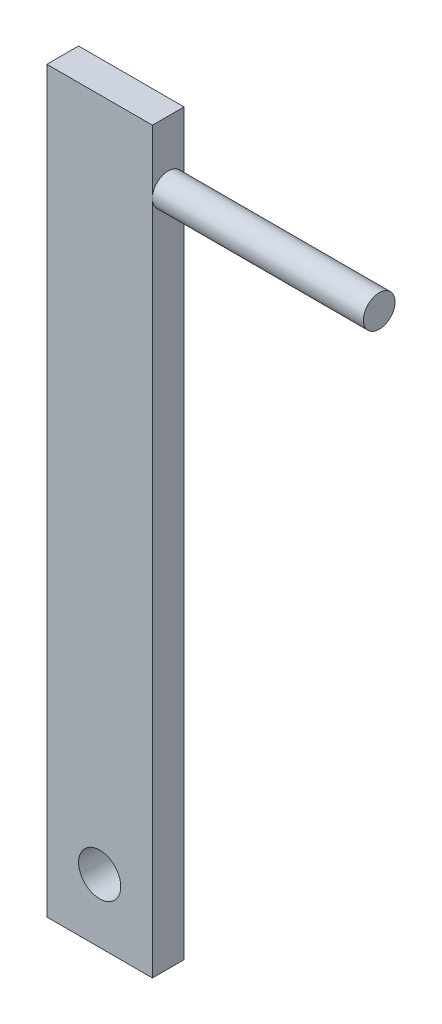
from build123d import *

# Parameters (mm, degrees)
SKETCH1_W               = 5
SKETCH1_H               = 1.5
BOSS_EXTRUDE1_DEPTH     = 35
SKETCH2_R               = 1
CUT_EXTRUDE1_DEPTH      = 1
CUT_EXTRUDE1_DEPTH_BACK = 2.5
SKETCH3_R               = 0.75
BOSS_EXTRUDE2_DEPTH     = 10


with BuildPart() as part:
    # Sketch1 → Boss-Extrude1 (new body)
    with BuildSketch(Plane(origin=(0, 0, 0), x_dir=(1, 0, 0), z_dir=(0, 1, 0))):
        with Locations((2.5, -0.75)):
            Rectangle(SKETCH1_W, SKETCH1_H)
    extrude(amount=BOSS_EXTRUDE1_DEPTH)

    # Sketch2 → Cut-Extrude1 (cut, two sides)
    with BuildSketch(Plane(origin=(0, 0, 0), x_dir=(-1, 0, 0), z_dir=(0, 0, -1))) as cut_extrude1_sk:
        with Locations((-2.5, 3)):
            Circle(SKETCH2_R)
    extrude(amount=CUT_EXTRUDE1_DEPTH, mode=Mode.SUBTRACT)
    extrude(cut_extrude1_sk.sketch, amount=-CUT_EXTRUDE1_DEPTH_BACK, mode=Mode.SUBTRACT)

    # Sketch3 → Boss-Extrude2 (add)
    with BuildSketch(Plane(origin=(5, 0, 0), x_dir=(0, 0, -1), z_dir=(1, 0, 0))):
        with Locations((-0.75, 32)):
            Circle(SKETCH3_R)
    extrude(amount=BOSS_EXTRUDE2_DEPTH)


solid = part.part
